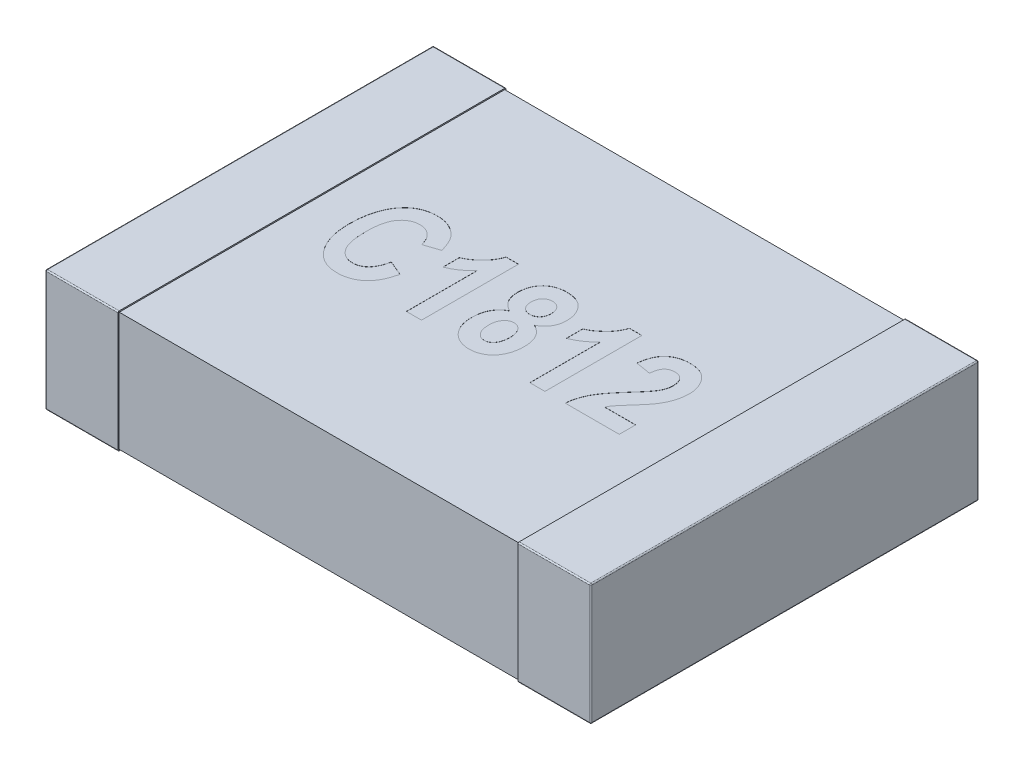
from build123d import *

# Parameters (mm, degrees)
SKETCH1_W            = 0.6
SKETCH1_H            = 3.2
THICKNESS_DEPTH      = 1
FILLET1_R            = 0.01
SKETCH2_W            = 3.18
SKETCH2_H            = 0.98
BOSS_EXTRUDE2_DEPTH  = 1.65
FILLET1_OF_MIRROR3_R = 0.01
CUT_EXTRUDE1_DEPTH   = 0.001


with BuildPart() as part:
    # Sketch1 → THICKNESS (new body)
    with BuildSketch(Plane(origin=(0, 0, 0), x_dir=(1, 0, 0), z_dir=(0, 1, 0))):
        with Locations((-1.95, 0)):
            Rectangle(SKETCH1_W, SKETCH1_H)
    thickness = extrude(amount=THICKNESS_DEPTH)

    # Fillet1
    fillet1_edges = [part.edges().sort_by_distance(p)[0] for p in [
        (-1.95, 1, -1.6),
        (-2.25, 1, 0),
        (-1.95, 0, -1.6),
        (-1.95, 0, 1.6),
        (-2.25, 0, 0),
        (-1.95, 1, 1.6),
        (-2.25, 0.5, -1.6),
        (-2.25, 0.5, 1.6),
    ]]
    fillet(fillet1_edges, radius=FILLET1_R)

    # Sketch2 → Boss-Extrude2 (add)
    with BuildSketch(Plane(origin=(0, 0, 0), x_dir=(0, 0, -1), z_dir=(1, 0, 0))):
        with Locations((0, 0.5)):
            Rectangle(SKETCH2_W, SKETCH2_H)
    boss_extrude2 = extrude(amount=-BOSS_EXTRUDE2_DEPTH)

    # Mirror3: THICKNESS, Boss-Extrude2 across plane
    add(thickness.mirror(Plane(origin=(0, 0, 0), x_dir=(0, 0, 1), z_dir=(1, 0, 0))))
    add(boss_extrude2.mirror(Plane(origin=(0, 0, 0), x_dir=(0, 0, 1), z_dir=(1, 0, 0))))

    # Fillet1 of Mirror3
    fillet1_of_mirror3_edges = [part.edges().sort_by_distance(p)[0] for p in [
        (1.95, 1, -1.6),
        (2.25, 1, 0),
        (1.95, 0, -1.6),
        (1.95, 0, 1.6),
        (2.25, 0, 0),
        (1.95, 1, 1.6),
        (2.25, 0.5, -1.6),
        (2.25, 0.5, 1.6),
    ]]
    fillet(fillet1_of_mirror3_edges, radius=FILLET1_OF_MIRROR3_R)

    # Sketch3 → Cut-Extrude1 (cut)
    with BuildSketch(Plane(origin=(0, 0.99, 0), x_dir=(1, 0, 0), z_dir=(0, 1, 0))):
        with BuildLine():
            Line((-0.886688312, -0.109090909), (-0.762012987, -0.161038961))
            add(Edge.make_bspline(
                [(-0.762012987, -0.161038961), (-0.764587888, -0.171519071), (-0.76960521, -0.191940082), (-0.779097291, -0.221127447), (-0.789542242, -0.248208875), (-0.801491852, -0.273032784), (-0.814536431, -0.29581696), (-0.829026304, -0.3163372), (-0.844688859, -0.334698569), (-0.861613178, -0.350858163), (-0.879771815, -0.364762202), (-0.898654923, -0.377152112), (-0.918750118, -0.3873092), (-0.939776014, -0.395885297), (-0.961897913, -0.402260201), (-0.984947737, -0.407057579), (-1.009024422, -0.409802863), (-1.025426179, -0.410191828), (-1.033766234, -0.41038961)],
                knots=[0, 0, 0, 0, 3.2366e-05, 6.3066e-05, 9.2006e-05, 0.00011938, 0.000145637, 0.000170679, 0.000194626, 0.000217936, 0.000240731, 0.000263155, 0.000285589, 0.000308168, 0.000331181, 0.00035455, 0.000378734, 0.000403753, 0.000403753, 0.000403753, 0.000403753], degree=3))
            add(Edge.make_bspline(
                [(-1.033766234, -0.41038961), (-1.044230463, -0.410154349), (-1.064729641, -0.409693477), (-1.094641881, -0.404734609), (-1.123105955, -0.397200474), (-1.150070553, -0.386381408), (-1.17556765, -0.372552339), (-1.199327892, -0.355423005), (-1.221905703, -0.335631103), (-1.235033145, -0.320199252), (-1.241720779, -0.312337662)],
                knots=[0, 0, 0, 0, 3.1365e-05, 6.1444e-05, 9.0703e-05, 0.000119552, 0.000148392, 0.000177492, 0.000207272, 0.000238198, 0.000238198, 0.000238198, 0.000238198], degree=3))
            add(Edge.make_bspline(
                [(-1.241720779, -0.312337662), (-1.249071833, -0.302631543), (-1.263881209, -0.283077668), (-1.282473559, -0.250833362), (-1.298286709, -0.216192275), (-1.311228993, -0.179123009), (-1.321316821, -0.139584496), (-1.328369523, -0.097557885), (-1.332604885, -0.053063505), (-1.333158439, -0.022574403), (-1.333441558, -0.006980519)],
                knots=[0, 0, 0, 0, 3.6498e-05, 7.3529e-05, 0.000111376, 0.000150601, 0.000191156, 0.000233644, 0.000278324, 0.0003251, 0.0003251, 0.0003251, 0.0003251], degree=3))
            add(Edge.make_bspline(
                [(-1.333441558, -0.006980519), (-1.333182908, 0.009481029), (-1.332679101, 0.041545363), (-1.328143083, 0.088227985), (-1.321228117, 0.132238588), (-1.31091819, 0.17341359), (-1.298002736, 0.211989422), (-1.282045729, 0.24772553), (-1.263518042, 0.280995659), (-1.248401568, 0.300865703), (-1.240909091, 0.310714286)],
                knots=[0, 0, 0, 0, 4.9372e-05, 9.6169e-05, 0.000140578, 0.000182904, 0.000223357, 0.000262454, 0.000300188, 0.000337271, 0.000337271, 0.000337271, 0.000337271], degree=3))
            add(Edge.make_bspline(
                [(-1.240909091, 0.310714286), (-1.234106292, 0.318675312), (-1.220699433, 0.334364788), (-1.197783924, 0.354681556), (-1.173165471, 0.371951533), (-1.146852985, 0.386091256), (-1.118728726, 0.397088672), (-1.08893034, 0.40484862), (-1.057338522, 0.4094273), (-1.035729472, 0.410063938), (-1.024675325, 0.41038961)],
                knots=[0, 0, 0, 0, 3.1385e-05, 6.1853e-05, 9.1577e-05, 0.000121428, 0.000151242, 0.000181955, 0.000213614, 0.000246771, 0.000246771, 0.000246771, 0.000246771], degree=3))
            add(Edge.make_bspline(
                [(-1.024675325, 0.41038961), (-1.015628999, 0.410173075), (-0.997848872, 0.409747484), (-0.971777538, 0.406345119), (-0.946938184, 0.400362535), (-0.923088339, 0.392515252), (-0.900437251, 0.382015668), (-0.878919422, 0.369275036), (-0.858450234, 0.354335243), (-0.846043536, 0.342720947), (-0.839772727, 0.336850649)],
                knots=[0, 0, 0, 0, 2.7134e-05, 5.3331e-05, 7.8689e-05, 0.000103689, 0.000128531, 0.000153422, 0.000178617, 0.000204367, 0.000204367, 0.000204367, 0.000204367], degree=3))
            add(Edge.make_bspline(
                [(-0.839772727, 0.336850649), (-0.835412695, 0.332326305), (-0.826528176, 0.323106963), (-0.81456515, 0.307577558), (-0.803489465, 0.290474927), (-0.793499694, 0.271726086), (-0.784212521, 0.251514282), (-0.775767536, 0.229735912), (-0.768338302, 0.20634143), (-0.764153998, 0.190118882), (-0.762012987, 0.181818182)],
                knots=[0, 0, 0, 0, 1.8838e-05, 3.8387e-05, 5.8695e-05, 7.9904e-05, 0.000102059, 0.000125392, 0.000149933, 0.000175647, 0.000175647, 0.000175647, 0.000175647], degree=3))
            Line((-0.762012987, 0.181818182), (-0.886688312, 0.14025974))
            add(Edge.make_bspline(
                [(-0.886688312, 0.14025974), (-0.887859879, 0.145580721), (-0.890139554, 0.155934467), (-0.894716563, 0.170876331), (-0.900288888, 0.184754353), (-0.90635165, 0.197901695), (-0.913652225, 0.20986361), (-0.921288857, 0.221211647), (-0.930243522, 0.231265568), (-0.939703879, 0.240553667), (-0.950003619, 0.248580124), (-0.960546329, 0.255838802), (-0.971646328, 0.26187386), (-0.983257314, 0.266727565), (-0.995241765, 0.270655679), (-1.007688983, 0.273418025), (-1.020570484, 0.275090808), (-1.029323898, 0.275245944), (-1.033766234, 0.275324675)],
                knots=[0, 0, 0, 0, 1.6341e-05, 3.1798e-05, 4.681e-05, 6.1188e-05, 7.5164e-05, 8.8809e-05, 0.000102156, 0.000115474, 0.000128531, 0.000141273, 0.00015384, 0.000166353, 0.000178982, 0.000191624, 0.000204551, 0.000217872, 0.000217872, 0.000217872, 0.000217872], degree=3))
            add(Edge.make_bspline(
                [(-1.033766234, 0.275324675), (-1.040053241, 0.275138273), (-1.052426715, 0.274771413), (-1.07055492, 0.271852603), (-1.087706664, 0.266690043), (-1.104140173, 0.259912618), (-1.119579304, 0.25088307), (-1.134195929, 0.239948161), (-1.147597023, 0.226777428), (-1.160440558, 0.211962615), (-1.172078974, 0.194797792), (-1.181960783, 0.174959821), (-1.190111483, 0.152519523), (-1.197132349, 0.127637839), (-1.202385248, 0.100151294), (-1.206030598, 0.070102452), (-1.208305708, 0.037534889), (-1.208609195, 0.014938972), (-1.208766234, 0.003246753)],
                knots=[0, 0, 0, 0, 1.8856e-05, 3.7111e-05, 5.4884e-05, 7.2491e-05, 9.0312e-05, 0.000108396, 0.00012711, 0.000146567, 0.000167144, 0.000189141, 0.000212873, 0.000238673, 0.000266626, 0.000296728, 0.000329437, 0.000364512, 0.000364512, 0.000364512, 0.000364512], degree=3))
            add(Edge.make_bspline(
                [(-1.208766234, 0.003246753), (-1.208588788, -0.008876697), (-1.208247081, -0.032222791), (-1.206255203, -0.065942376), (-1.202469117, -0.096922951), (-1.197622639, -0.125286334), (-1.190990688, -0.150866739), (-1.182888479, -0.173679833), (-1.173556023, -0.193948332), (-1.162423404, -0.21140631), (-1.150088241, -0.226477742), (-1.136973708, -0.239563029), (-1.122826613, -0.250493966), (-1.108025428, -0.259757872), (-1.0921638, -0.266777814), (-1.075429381, -0.271554026), (-1.057921414, -0.2748575), (-1.04590329, -0.275166865), (-1.039772727, -0.275324675)],
                knots=[0, 0, 0, 0, 3.6373e-05, 7.0043e-05, 0.000101273, 0.000129965, 0.000156307, 0.00018044, 0.000202516, 0.000223097, 0.000242366, 0.000260848, 0.000278545, 0.000295891, 0.000313116, 0.000330376, 0.000348017, 0.000366387, 0.000366387, 0.000366387, 0.000366387], degree=3))
            add(Edge.make_bspline(
                [(-1.039772727, -0.275324675), (-1.035276477, -0.275185424), (-1.026357177, -0.274909188), (-1.013232349, -0.273150197), (-1.00056711, -0.270005154), (-0.988359752, -0.265641764), (-0.976662302, -0.259884829), (-0.965354745, -0.253064532), (-0.954665507, -0.244866461), (-0.944317228, -0.235557954), (-0.934556934, -0.224851527), (-0.925636771, -0.21254215), (-0.917348931, -0.198849825), (-0.909743519, -0.183689634), (-0.902772029, -0.167159014), (-0.896625224, -0.149131112), (-0.891062936, -0.129695933), (-0.888174607, -0.116091544), (-0.886688312, -0.109090909)],
                knots=[0, 0, 0, 0, 1.349e-05, 2.676e-05, 3.9635e-05, 5.2575e-05, 6.5571e-05, 7.8684e-05, 9.2126e-05, 0.000105918, 0.000120398, 0.000135496, 0.000151449, 0.000168365, 0.000186335, 0.000205227, 0.000225475, 0.000246939, 0.000246939, 0.000246939, 0.000246939], degree=3))
        make_face()
        with BuildLine():
            Line((-0.346428571, -0.4), (-0.471103896, -0.4))
            Line((-0.471103896, -0.4), (-0.471103896, 0.181818182))
            add(Edge.make_bspline(
                [(-0.471103896, 0.181818182), (-0.477150623, 0.175473091), (-0.489142698, 0.162889291), (-0.508221205, 0.145321837), (-0.527959547, 0.129125556), (-0.548487968, 0.11422702), (-0.569571575, 0.100484821), (-0.591477089, 0.088080675), (-0.614018763, 0.076988684), (-0.629559083, 0.070686815), (-0.637337662, 0.067532468)],
                knots=[0, 0, 0, 0, 2.6289e-05, 5.2138e-05, 7.7746e-05, 0.000102846, 0.000128196, 0.000153205, 0.000178325, 0.0002035, 0.0002035, 0.0002035, 0.0002035], degree=3))
            Line((-0.637337662, 0.067532468), (-0.637337662, 0.202597403))
            add(Edge.make_bspline(
                [(-0.637337662, 0.202597403), (-0.628371684, 0.206582281), (-0.609705024, 0.214878574), (-0.582396668, 0.231535803), (-0.55481633, 0.252395472), (-0.531931447, 0.272419113), (-0.51408208, 0.29023418), (-0.501363771, 0.304265743), (-0.489977606, 0.319086366), (-0.479425534, 0.334167018), (-0.470108745, 0.349938964), (-0.461883323, 0.366099424), (-0.454584525, 0.382753814), (-0.45077734, 0.39423095), (-0.448863636, 0.4)],
                knots=[0, 0, 0, 0, 2.9412e-05, 6.1234e-05, 9.5682e-05, 0.000133066, 0.000152351, 0.00017132, 0.000189829, 0.000208382, 0.000226506, 0.000244729, 0.000262763, 0.000280989, 0.000280989, 0.000280989, 0.000280989], degree=3))
            Line((-0.448863636, 0.4), (-0.346428571, 0.4))
            Line((-0.346428571, 0.4), (-0.346428571, -0.4))
        make_face()
        with BuildLine():
            add(Edge.make_bspline(
                [(-0.049025974, 0.030194805), (-0.056961649, 0.034289498), (-0.072393267, 0.042251989), (-0.092687833, 0.057866208), (-0.11014289, 0.075289566), (-0.124466535, 0.095053818), (-0.135608703, 0.117017351), (-0.143309459, 0.141142576), (-0.148157107, 0.167285213), (-0.148729703, 0.185421294), (-0.149025974, 0.194805195)],
                knots=[0, 0, 0, 0, 2.6742e-05, 5.2002e-05, 7.6453e-05, 0.000100514, 0.000124908, 0.000150012, 0.000176249, 0.00020438, 0.00020438, 0.00020438, 0.00020438], degree=3))
            add(Edge.make_bspline(
                [(-0.149025974, 0.194805195), (-0.148890837, 0.202442803), (-0.148627391, 0.217332067), (-0.145973124, 0.23906742), (-0.141595765, 0.259598346), (-0.135561916, 0.278993004), (-0.128033077, 0.297339929), (-0.118285355, 0.314262032), (-0.107103341, 0.330091797), (-0.094237659, 0.34455496), (-0.079933155, 0.357571406), (-0.06431889, 0.36895612), (-0.047466537, 0.378651123), (-0.029374701, 0.386338249), (-0.01023269, 0.392637494), (0.010124495, 0.396930514), (0.031692052, 0.399606254), (0.046474437, 0.399866489), (0.054058442, 0.4)],
                knots=[0, 0, 0, 0, 2.2904e-05, 4.4651e-05, 6.5569e-05, 8.58e-05, 0.000105518, 0.000124928, 0.000144253, 0.000163572, 0.000182878, 0.000202166, 0.000221435, 0.000241068, 0.000261038, 0.000281798, 0.000303383, 0.000326125, 0.000326125, 0.000326125, 0.000326125], degree=3))
            add(Edge.make_bspline(
                [(0.054058442, 0.4), (0.062075248, 0.399811515), (0.077617509, 0.399446096), (0.100234222, 0.396663258), (0.12133993, 0.392011797), (0.141017812, 0.385444947), (0.159305494, 0.37725539), (0.176027567, 0.366900237), (0.191211201, 0.354650482), (0.204773826, 0.340619318), (0.216923284, 0.32546527), (0.22732873, 0.309231757), (0.23631639, 0.29232579), (0.243699728, 0.27457668), (0.249111212, 0.255974301), (0.253255476, 0.236675322), (0.255715244, 0.216513875), (0.256015981, 0.202766417), (0.256168831, 0.195779221)],
                knots=[0, 0, 0, 0, 2.4046e-05, 4.6618e-05, 6.824e-05, 8.8775e-05, 0.000108753, 0.000128215, 0.00014761, 0.000167126, 0.000186647, 0.000205785, 0.000224883, 0.000244027, 0.000263339, 0.00028292, 0.000303196, 0.000324154, 0.000324154, 0.000324154, 0.000324154], degree=3))
            add(Edge.make_bspline(
                [(0.256168831, 0.195779221), (0.255911571, 0.186388447), (0.25541062, 0.168102179), (0.249925656, 0.141702748), (0.241678815, 0.117056292), (0.229441072, 0.094783383), (0.214620369, 0.074698068), (0.197260686, 0.056968797), (0.177307562, 0.041799861), (0.162411335, 0.034095256), (0.15487013, 0.030194805)],
                knots=[0, 0, 0, 0, 2.8131e-05, 5.4779e-05, 8.0551e-05, 0.000105829, 0.000130667, 0.000155233, 0.000180038, 0.000205471, 0.000205471, 0.000205471, 0.000205471], degree=3))
            add(Edge.make_bspline(
                [(0.15487013, 0.030194805), (0.163810512, 0.025549017), (0.181288056, 0.01646697), (0.204124514, -0.001639534), (0.223826449, -0.021981465), (0.239524363, -0.045486042), (0.251840271, -0.071566277), (0.260321322, -0.100487153), (0.265610926, -0.13211172), (0.266234607, -0.154144365), (0.266558442, -0.165584416)],
                knots=[0, 0, 0, 0, 3.0164e-05, 5.8967e-05, 8.6984e-05, 0.00011481, 0.000143349, 0.000173188, 0.000204947, 0.000239247, 0.000239247, 0.000239247, 0.000239247], degree=3))
            add(Edge.make_bspline(
                [(0.266558442, -0.165584416), (0.266296793, -0.177457267), (0.265786334, -0.200620367), (0.260354769, -0.234236613), (0.25207578, -0.265862021), (0.240059298, -0.295010947), (0.225119754, -0.321374505), (0.207674505, -0.344804252), (0.187328186, -0.364794847), (0.164542718, -0.381357287), (0.139802517, -0.394493006), (0.113249589, -0.403495834), (0.085387858, -0.409501431), (0.066211524, -0.410090889), (0.056493506, -0.41038961)],
                knots=[0, 0, 0, 0, 3.5589e-05, 6.9432e-05, 0.00010188, 0.000133474, 0.000163717, 0.000192581, 0.00022082, 0.00024894, 0.000276824, 0.000304497, 0.000332832, 0.000361945, 0.000361945, 0.000361945, 0.000361945], degree=3))
            add(Edge.make_bspline(
                [(0.056493506, -0.41038961), (0.048851687, -0.410226311), (0.033827804, -0.409905264), (0.011824743, -0.406664674), (-0.009219653, -0.40175674), (-0.029145663, -0.394484672), (-0.04813916, -0.385400342), (-0.066027343, -0.374076348), (-0.083031047, -0.36090887), (-0.09871715, -0.345627403), (-0.112954758, -0.328685067), (-0.125380338, -0.310162735), (-0.135954767, -0.290319595), (-0.144603386, -0.269052508), (-0.15126761, -0.246369539), (-0.155853622, -0.222277793), (-0.158908476, -0.196831112), (-0.159243747, -0.179392425), (-0.159415584, -0.170454545)],
                knots=[0, 0, 0, 0, 2.291e-05, 4.5042e-05, 6.658e-05, 8.7634e-05, 0.000108544, 0.000129624, 0.000151023, 0.000172951, 0.000195191, 0.000217298, 0.000239739, 0.00026253, 0.000286056, 0.000310539, 0.000336031, 0.000362835, 0.000362835, 0.000362835, 0.000362835], degree=3))
            add(Edge.make_bspline(
                [(-0.159415584, -0.170454545), (-0.159099384, -0.158959762), (-0.158487131, -0.136702627), (-0.153010205, -0.104578718), (-0.144170569, -0.074939722), (-0.131562525, -0.04788236), (-0.115620965, -0.02361732), (-0.096576145, -0.002182855), (-0.074324273, 0.016102866), (-0.057519346, 0.025463733), (-0.049025974, 0.030194805)],
                knots=[0, 0, 0, 0, 3.4462e-05, 6.6728e-05, 9.7438e-05, 0.000126996, 0.000155948, 0.000184232, 0.00021273, 0.000241851, 0.000241851, 0.000241851, 0.000241851], degree=3))
        make_face()
        with BuildLine():
            add(Edge.make_bspline(
                [(-0.024350649, 0.18262987), (-0.024105146, 0.1754607), (-0.023638642, 0.161837922), (-0.019211523, 0.14268253), (-0.011964929, 0.126030508), (-0.001487444, 0.11238673), (0.011002662, 0.101542326), (0.025433726, 0.093990918), (0.041230066, 0.088988052), (0.052395645, 0.08854084), (0.058116883, 0.088311688)],
                knots=[0, 0, 0, 0, 2.1478e-05, 4.0813e-05, 5.8615e-05, 7.553e-05, 9.1994e-05, 0.000107827, 0.000124107, 0.000141215, 0.000141215, 0.000141215, 0.000141215], degree=3))
            add(Edge.make_bspline(
                [(0.058116883, 0.088311688), (0.063944725, 0.088542885), (0.075319427, 0.088994131), (0.091400564, 0.093953679), (0.106033842, 0.101538569), (0.118690332, 0.112375238), (0.129319437, 0.126017694), (0.136781826, 0.142643257), (0.141158592, 0.161842969), (0.141633297, 0.17546244), (0.141883117, 0.18262987)],
                knots=[0, 0, 0, 0, 1.7431e-05, 3.4023e-05, 4.9999e-05, 6.6586e-05, 8.36e-05, 0.000101469, 0.000120804, 0.000142282, 0.000142282, 0.000142282, 0.000142282], degree=3))
            add(Edge.make_bspline(
                [(0.141883117, 0.18262987), (0.141632254, 0.189581166), (0.141154253, 0.202826359), (0.136770143, 0.22147464), (0.1293554, 0.237694757), (0.119044228, 0.251278908), (0.10650062, 0.261994784), (0.092352475, 0.269895866), (0.07659071, 0.274582722), (0.065561953, 0.275073061), (0.059902597, 0.275324675)],
                knots=[0, 0, 0, 0, 2.0831e-05, 3.9691e-05, 5.705e-05, 7.3966e-05, 9.0429e-05, 0.000106197, 0.000122275, 0.000139221, 0.000139221, 0.000139221, 0.000139221], degree=3))
            add(Edge.make_bspline(
                [(0.059902597, 0.275324675), (0.054022043, 0.275090615), (0.04254387, 0.274633756), (0.026264532, 0.269706753), (0.011509796, 0.261969013), (-0.001100132, 0.250932833), (-0.01175278, 0.237409212), (-0.018947505, 0.221034499), (-0.023683941, 0.202592525), (-0.024121848, 0.189480667), (-0.024350649, 0.18262987)],
                knots=[0, 0, 0, 0, 1.7593e-05, 3.434e-05, 5.0536e-05, 6.7228e-05, 8.4242e-05, 0.000101749, 0.00012049, 0.000140997, 0.000140997, 0.000140997, 0.000140997], degree=3))
        make_face(mode=Mode.SUBTRACT)
        with BuildLine():
            add(Edge.make_bspline(
                [(-0.03474026, -0.155519481), (-0.034484294, -0.165340079), (-0.033998203, -0.183989845), (-0.028914, -0.210136463), (-0.02092847, -0.232967466), (-0.00939009, -0.251943003), (0.00463015, -0.26677315), (0.020030019, -0.277803168), (0.03703609, -0.284516879), (0.048915127, -0.285314457), (0.05487013, -0.285714286)],
                knots=[0, 0, 0, 0, 2.9428e-05, 5.5885e-05, 7.956e-05, 0.000101639, 0.000121965, 0.000140384, 0.000158112, 0.000175932, 0.000175932, 0.000175932, 0.000175932], degree=3))
            add(Edge.make_bspline(
                [(0.05487013, -0.285714286), (0.060827435, -0.28538414), (0.072596347, -0.284731924), (0.089262537, -0.278127894), (0.104241375, -0.267659471), (0.115205054, -0.256020051), (0.122783177, -0.244747692), (0.128053117, -0.235191103), (0.132209049, -0.224448759), (0.135762333, -0.212844429), (0.138551216, -0.200197614), (0.140389148, -0.186512503), (0.141800609, -0.171836295), (0.141855161, -0.161692044), (0.141883117, -0.156493506)],
                knots=[0, 0, 0, 0, 1.7802e-05, 3.5168e-05, 5.291e-05, 7.2318e-05, 8.2719e-05, 9.3615e-05, 0.00010498, 0.000117201, 0.000130002, 0.000143777, 0.000158607, 0.000174195, 0.000174195, 0.000174195, 0.000174195], degree=3))
            add(Edge.make_bspline(
                [(0.141883117, -0.156493506), (0.14158772, -0.14770534), (0.141024986, -0.130963771), (0.136357599, -0.107176263), (0.128282188, -0.086276945), (0.116991313, -0.068629851), (0.103595394, -0.054338986), (0.08826087, -0.043949656), (0.071290895, -0.037343386), (0.05931214, -0.036692971), (0.053246753, -0.036363636)],
                knots=[0, 0, 0, 0, 2.6349e-05, 5.0195e-05, 7.2352e-05, 9.3157e-05, 0.000112677, 0.000130687, 0.000148357, 0.000166481, 0.000166481, 0.000166481, 0.000166481], degree=3))
            add(Edge.make_bspline(
                [(0.053246753, -0.036363636), (0.047297946, -0.036783445), (0.035520018, -0.037614615), (0.018598725, -0.043919308), (0.003383141, -0.054538111), (-0.009961313, -0.068937057), (-0.021263519, -0.086487716), (-0.029177717, -0.107202042), (-0.033874127, -0.130525407), (-0.034443176, -0.146946517), (-0.03474026, -0.155519481)],
                knots=[0, 0, 0, 0, 1.782e-05, 3.5282e-05, 5.3383e-05, 7.3021e-05, 9.3826e-05, 0.000115621, 0.000139149, 0.00016485, 0.00016485, 0.00016485, 0.00016485], degree=3))
        make_face(mode=Mode.SUBTRACT)
        with BuildLine():
            Line((0.671753247, -0.4), (0.547077922, -0.4))
            Line((0.547077922, -0.4), (0.547077922, 0.181818182))
            add(Edge.make_bspline(
                [(0.547077922, 0.181818182), (0.541031195, 0.175473091), (0.529039121, 0.162889291), (0.509960613, 0.145321837), (0.490222271, 0.129125556), (0.46969385, 0.11422702), (0.448610243, 0.100484821), (0.426704729, 0.088080675), (0.404163055, 0.076988684), (0.388622735, 0.070686815), (0.380844156, 0.067532468)],
                knots=[0, 0, 0, 0, 2.6289e-05, 5.2138e-05, 7.7746e-05, 0.000102846, 0.000128196, 0.000153205, 0.000178325, 0.0002035, 0.0002035, 0.0002035, 0.0002035], degree=3))
            Line((0.380844156, 0.067532468), (0.380844156, 0.202597403))
            add(Edge.make_bspline(
                [(0.380844156, 0.202597403), (0.389810134, 0.206582281), (0.408476794, 0.214878574), (0.43578515, 0.231535803), (0.463365489, 0.252395472), (0.486250371, 0.272419113), (0.504099738, 0.29023418), (0.516818047, 0.304265743), (0.528204212, 0.319086366), (0.538756284, 0.334167018), (0.548073073, 0.349938964), (0.556298495, 0.366099424), (0.563597293, 0.382753814), (0.567404478, 0.39423095), (0.569318182, 0.4)],
                knots=[0, 0, 0, 0, 2.9412e-05, 6.1234e-05, 9.5682e-05, 0.000133066, 0.000152351, 0.00017132, 0.000189829, 0.000208382, 0.000226506, 0.000244729, 0.000262763, 0.000280989, 0.000280989, 0.000280989, 0.000280989], degree=3))
            Line((0.569318182, 0.4), (0.671753247, 0.4))
            Line((0.671753247, 0.4), (0.671753247, -0.4))
        make_face()
        with BuildLine():
            Line((1.28474026, -0.264935065), (1.28474026, -0.4))
            Line((1.28474026, -0.4), (0.837987013, -0.4))
            add(Edge.make_bspline(
                [(0.837987013, -0.4), (0.839558894, -0.386697502), (0.842698386, -0.36012865), (0.852204916, -0.321133588), (0.865019576, -0.283038878), (0.879051677, -0.252019348), (0.892976781, -0.226973436), (0.90543373, -0.206538009), (0.920268606, -0.18479262), (0.937463682, -0.161766733), (0.95652991, -0.137119139), (0.977888972, -0.111108348), (1.001429629, -0.083711455), (1.018041212, -0.065122981), (1.026623377, -0.055519481)],
                knots=[0, 0, 0, 0, 4.0154e-05, 8.0199e-05, 0.000120138, 0.000160605, 0.000182112, 0.000206084, 0.000232379, 0.000261049, 0.000292287, 0.000325856, 0.000362005, 0.000400643, 0.000400643, 0.000400643, 0.000400643], degree=3))
            add(Edge.make_bspline(
                [(1.026623377, -0.055519481), (1.033352352, -0.048014585), (1.046225482, -0.033657051), (1.064332658, -0.012865993), (1.080620008, 0.005830232), (1.094568476, 0.022817589), (1.106669561, 0.037740884), (1.116698389, 0.050827608), (1.124775235, 0.061964315), (1.129092309, 0.068971117), (1.131006494, 0.072077922)],
                knots=[0, 0, 0, 0, 3.0239e-05, 5.785e-05, 8.2712e-05, 0.00010462, 0.000123787, 0.000140346, 0.000154084, 0.000165029, 0.000165029, 0.000165029, 0.000165029], degree=3))
            add(Edge.make_bspline(
                [(1.131006494, 0.072077922), (1.135449026, 0.08003614), (1.144120948, 0.095570757), (1.153151385, 0.120188111), (1.159054047, 0.144849846), (1.159730462, 0.161439573), (1.160064935, 0.169642857)],
                knots=[0, 0, 0, 0, 2.7302e-05, 5.3294e-05, 7.8421e-05, 0.000102999, 0.000102999, 0.000102999, 0.000102999], degree=3))
            add(Edge.make_bspline(
                [(1.160064935, 0.169642857), (1.159777646, 0.177839192), (1.159233788, 0.193355379), (1.154579315, 0.215034129), (1.14679817, 0.233677557), (1.135551297, 0.248814461), (1.121859239, 0.260696351), (1.10606645, 0.269366854), (1.08819287, 0.274503152), (1.075629055, 0.275045331), (1.069155844, 0.275324675)],
                knots=[0, 0, 0, 0, 2.4567e-05, 4.6506e-05, 6.6138e-05, 8.471e-05, 0.000102548, 0.000120129, 0.000138369, 0.000157755, 0.000157755, 0.000157755, 0.000157755], degree=3))
            add(Edge.make_bspline(
                [(1.069155844, 0.275324675), (1.06213633, 0.275017935), (1.048682201, 0.274430015), (1.029759489, 0.268956417), (1.013335548, 0.259933531), (0.999876626, 0.24683813), (0.988830545, 0.23047763), (0.9808555, 0.210366892), (0.975387639, 0.186887964), (0.973861552, 0.169998821), (0.973051948, 0.161038961)],
                knots=[0, 0, 0, 0, 2.1018e-05, 4.0284e-05, 5.8527e-05, 7.667e-05, 9.6076e-05, 0.00011733, 0.000141191, 0.000168154, 0.000168154, 0.000168154, 0.000168154], degree=3))
            Line((0.973051948, 0.161038961), (0.848376623, 0.181818182))
            add(Edge.make_bspline(
                [(0.848376623, 0.181818182), (0.849420608, 0.190931945), (0.851445816, 0.208611567), (0.856808461, 0.234005887), (0.863159379, 0.257610097), (0.871111506, 0.279302039), (0.88054175, 0.299110008), (0.891482062, 0.317012169), (0.903617005, 0.333309759), (0.917559, 0.347452128), (0.93275171, 0.359824844), (0.949092597, 0.370654268), (0.966701968, 0.379709709), (0.985426227, 0.387260937), (1.005434842, 0.392851514), (1.026524262, 0.397131357), (1.048861514, 0.399545309), (1.064117822, 0.399846206), (1.071915584, 0.4)],
                knots=[0, 0, 0, 0, 2.7506e-05, 5.3358e-05, 7.7776e-05, 0.000100785, 0.000122568, 0.000143477, 0.00016364, 0.000183385, 0.000202882, 0.000222333, 0.000242082, 0.000262189, 0.000282793, 0.000304315, 0.000326688, 0.000350079, 0.000350079, 0.000350079, 0.000350079], degree=3))
            add(Edge.make_bspline(
                [(1.071915584, 0.4), (1.080479088, 0.39986209), (1.097077514, 0.399594783), (1.121122262, 0.396125928), (1.143635065, 0.391183541), (1.16439441, 0.383495797), (1.183763241, 0.374248192), (1.201180425, 0.362276534), (1.217360383, 0.348708086), (1.231232535, 0.332599783), (1.243860289, 0.31557323), (1.254702654, 0.297628202), (1.264090391, 0.279241064), (1.271571104, 0.260083004), (1.277394981, 0.240302809), (1.281592036, 0.219942609), (1.284341169, 0.198992876), (1.28460585, 0.18480318), (1.28474026, 0.177597403)],
                knots=[0, 0, 0, 0, 2.5668e-05, 4.9751e-05, 7.2748e-05, 9.4676e-05, 0.000116021, 0.000136957, 0.000157911, 0.000179184, 0.000200549, 0.000221458, 0.000242004, 0.000262412, 0.000283062, 0.000303788, 0.000324729, 0.000346335, 0.000346335, 0.000346335, 0.000346335], degree=3))
            add(Edge.make_bspline(
                [(1.28474026, 0.177597403), (1.284603848, 0.169418548), (1.284333029, 0.15318104), (1.281551718, 0.129001359), (1.277443839, 0.105158636), (1.27135019, 0.081620805), (1.263470453, 0.05826813), (1.253875284, 0.034898434), (1.242505886, 0.011435015), (1.231310206, -0.00800582), (1.221278667, -0.024156963), (1.21234589, -0.037066696), (1.202165656, -0.050731388), (1.191023382, -0.065380962), (1.178482175, -0.080733427), (1.164847867, -0.096971484), (1.150072784, -0.114018831), (1.13973548, -0.125556081), (1.134415584, -0.131493506)],
                knots=[0, 0, 0, 0, 2.4526e-05, 4.8692e-05, 7.2926e-05, 9.7062e-05, 0.00012155, 0.000146812, 0.000172805, 0.000199706, 0.000214074, 0.000229834, 0.000246783, 0.000265193, 0.000285045, 0.000306246, 0.000328802, 0.000352718, 0.000352718, 0.000352718, 0.000352718], degree=3))
            add(Edge.make_bspline(
                [(1.134415584, -0.131493506), (1.129489515, -0.136957125), (1.120097882, -0.147373604), (1.106702224, -0.162289894), (1.094975023, -0.175973669), (1.084346287, -0.187926932), (1.075280491, -0.198500584), (1.067546515, -0.207563235), (1.061488611, -0.215381709), (1.052313036, -0.226804534), (1.041293539, -0.242883331), (1.03347176, -0.257770915), (1.029707792, -0.264935065)],
                knots=[0, 0, 0, 0, 2.207e-05, 4.2076e-05, 6.0142e-05, 7.6131e-05, 9.0059e-05, 0.000101928, 0.000111866, 0.000119726, 0.000145887, 0.000170154, 0.000170154, 0.000170154, 0.000170154], degree=3))
            Line((1.029707792, -0.264935065), (1.28474026, -0.264935065))
        make_face()
    extrude(amount=-CUT_EXTRUDE1_DEPTH, mode=Mode.SUBTRACT)


solid = part.part
